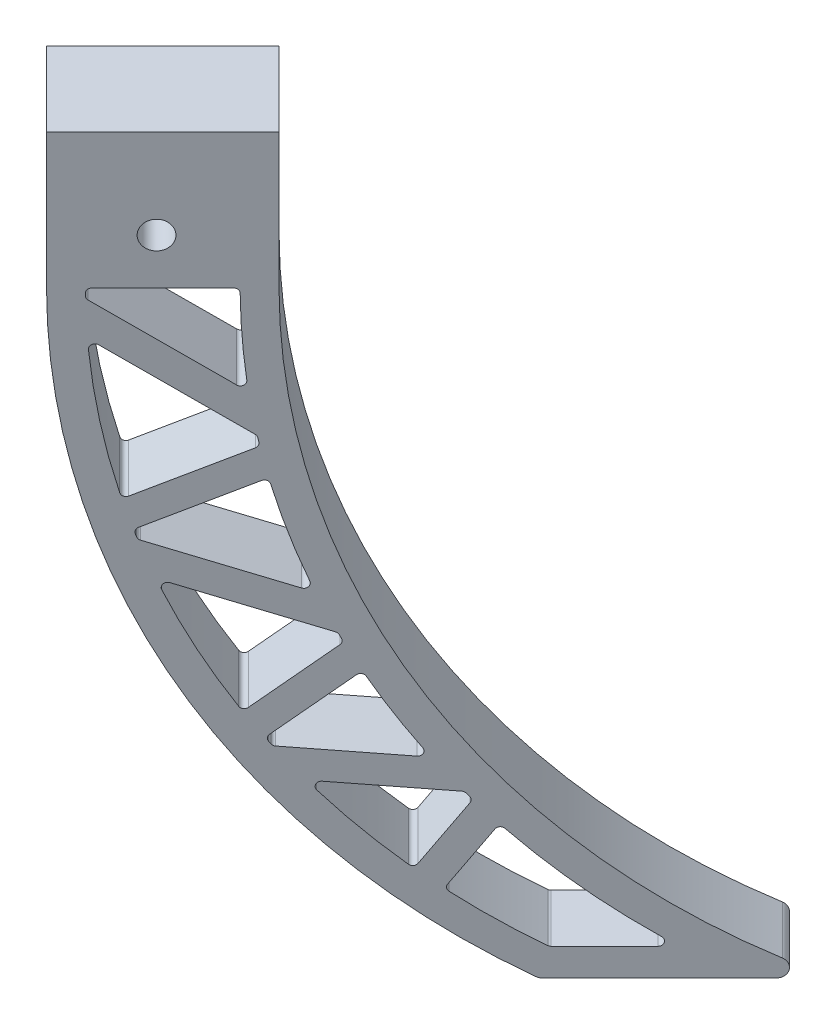
from build123d import *

# Parameters (mm, degrees)
BOSS_EXTRUDE1_DEPTH      = 40
BOSS_EXTRUDE1_DEPTH_BACK = 40
CUT_EXTRUDE1_DEPTH       = 30
CUT_EXTRUDE1_DEPTH_BACK  = 207.92123274
SKETCH3_R                = 1.5
CUT_EXTRUDE2_DEPTH       = 206.675682312
FILLET1_R                = 1
CUT_EXTRUDE3_DEPTH       = 40
FILLET2_R                = 0.5


with BuildPart() as part:
    # Sketch1 → Boss-Extrude1 (new, two sides: drawn at the far end of the back side and taken through both)
    with BuildSketch(Plane(origin=(61.148873397, 0, -61.148873397), x_dir=(0.7071067811865499, 0, 0.7071067811865452), z_dir=(-0.7071067811865452, 0, 0.7071067811865499)).offset(-BOSS_EXTRUDE1_DEPTH_BACK)):
        Polygon((-3.75, -92.901515315), (-3.75, -84.066578824), (-7.75, -81.757177748), (-7.75, -79.151515315), (3.75, -79.151515315), (3.75, -92.901515315), (3.75, -159.151515315), (-3.75, -159.151515315), align=None)
    extrude(amount=BOSS_EXTRUDE1_DEPTH + BOSS_EXTRUDE1_DEPTH_BACK)

    # Sketch2 → Cut-Extrude1 (cut, two sides: drawn at the far end of the back side and taken through both)
    with BuildSketch(Plane(origin=(-2.651650429, 0, -2.651650429), x_dir=(-0.7071067811865454, 0, 0.7071067811865498), z_dir=(-0.7071067811865498, 0, -0.7071067811865454)).offset(-CUT_EXTRUDE1_DEPTH_BACK)):
        with BuildLine():
            Line((-83.584702548, -79.151515315), (-83.584702548, -93.901515315))
            ThreePointArc((-83.584702548, -93.901515315), (-95.268174411, -132.944313121), (-126.477566081, -159.151515315))
            Line((-126.477566081, -159.151515315), (-126.477566081, -79.151515315))
            Line((-126.477566081, -79.151515315), (-83.584702548, -79.151515315))
        make_face()
        with BuildLine():
            Line((-65.634702548, -93.901515315), (-65.634702548, -79.151515315))
            Line((-65.634702548, -79.151515315), (-46.477566081, -79.151515315))
            Line((-46.477566081, -79.151515315), (-46.477566081, -159.151515315))
            Line((-46.477566081, -159.151515315), (-103.655823441, -159.151515315))
            ThreePointArc((-103.655823441, -159.151515315), (-75.833406523, -131.661176774), (-65.634702548, -93.901515315))
        make_face()
    extrude(amount=CUT_EXTRUDE1_DEPTH + CUT_EXTRUDE1_DEPTH_BACK, mode=Mode.SUBTRACT)

    # Sketch3 → Cut-Extrude2 (cut, through all)
    with BuildSketch(Plane(origin=(2.651650429, 0, 2.651650429), x_dir=(0.7071067811865454, 0, -0.7071067811865498), z_dir=(0.7071067811865498, 0, 0.7071067811865454))):
        with Locations((74.128214207, -88.901515315)):
            Circle(SKETCH3_R)
    extrude(amount=-CUT_EXTRUDE2_DEPTH, mode=Mode.SUBTRACT)

    # Fillet1
    fillet1_edges = [part.edges().sort_by_distance(p)[0] for p in [
        (73.295735665, -159.151515315, -73.295735665),
        (89.433144644, -159.151515315, -89.433144644),
    ]]
    fillet(fillet1_edges, radius=FILLET1_R)

    # Sketch4 → Cut-Extrude3 (cut)
    with BuildSketch(Plane(origin=(-2.651650429, 0, -2.651650429), x_dir=(-0.7071067811865454, 0, 0.7071067811865498), z_dir=(-0.7071067811865498, 0, -0.7071067811865454))):
        with BuildLine():
            ThreePointArc((-68.641647327, -94.901515315), (-68.636438764, -94.401527372), (-68.634702548, -93.901515315))
            Line((-68.634702548, -93.901515315), (-80.584702548, -93.901515315))
            ThreePointArc((-80.584702548, -93.901515315), (-80.748343571, -98.82260697), (-81.238542868, -103.721956531))
            Line((-81.238542868, -103.721956531), (-68.641647327, -94.901515315))
        make_face()
        with BuildLine():
            ThreePointArc((-71.446777789, -113.827153762), (-69.713665767, -106.319507983), (-68.79275862, -98.669648347))
            Line((-68.79275862, -98.669648347), (-81.910741312, -107.854958715))
            ThreePointArc((-81.910741312, -107.854958715), (-82.008492364, -108.355301003), (-82.109684478, -108.854958715))
            Line((-82.109684478, -108.854958715), (-71.446777789, -113.827153762))
        make_face()
        with BuildLine():
            ThreePointArc((-72.669081723, -117.664393631), (-72.505700586, -117.19183716), (-72.34560503, -116.718157493))
            Line((-72.34560503, -116.718157493), (-82.791324081, -111.847238704))
            ThreePointArc((-82.791324081, -111.847238704), (-84.384922058, -117.323155489), (-86.395070265, -122.660244896))
            Line((-86.395070265, -122.660244896), (-72.669081723, -117.664393631))
        make_face()
        with BuildLine():
            ThreePointArc((-80.784042437, -133.925239334), (-77.121371127, -127.814001685), (-74.080630429, -121.370688662))
            Line((-74.080630429, -121.370688662), (-88.136449193, -126.48658831))
            ThreePointArc((-88.136449193, -126.48658831), (-88.357906284, -126.934873492), (-88.582384151, -127.381653678))
            Line((-88.582384151, -127.381653678), (-80.784042437, -133.925239334))
        make_face()
        with BuildLine():
            ThreePointArc((-83.105887337, -137.19626581), (-82.806616537, -136.795716185), (-82.510134547, -136.393097949))
            Line((-82.510134547, -136.393097949), (-90.024605255, -130.087708349))
            ThreePointArc((-90.024605255, -130.087708349), (-92.547245897, -134.264707863), (-95.339415884, -138.266560873))
            Line((-95.339415884, -138.266560873), (-83.105887337, -137.19626581))
        make_face()
        with BuildLine():
            ThreePointArc((-94.002421329, -148.759790428), (-89.676742116, -144.76688928), (-85.691714117, -140.433955852))
            Line((-85.691714117, -140.433955852), (-97.902966063, -141.502301965))
            ThreePointArc((-97.902966063, -141.502301965), (-98.225553246, -141.884323374), (-98.550711636, -142.264158692))
            Line((-98.550711636, -142.264158692), (-94.002421329, -148.759790428))
        make_face()
        with BuildLine():
            ThreePointArc((-104.455461262, -156.151515315), (-100.301370683, -153.543969496), (-96.334442354, -150.659659636))
            Line((-96.334442354, -150.659659636), (-100.609312238, -144.554512732))
            ThreePointArc((-100.609312238, -144.554512732), (-107.203125114, -150.779152155), (-114.508069897, -156.151515315))
            Line((-114.508069897, -156.151515315), (-104.455461262, -156.151515315))
        make_face()
    extrude(amount=-CUT_EXTRUDE3_DEPTH, mode=Mode.SUBTRACT)

    # Fillet2
    fillet2_edges = [part.edges().sort_by_distance(p)[0] for p in [
        (80.969432725, -156.151515315, -80.969432725),
        (71.141526934, -144.554512732, -71.141526934),
        (68.11873745, -150.659659636, -68.11873745),
        (73.86116499, -156.151515315, -73.86116499),
        (66.46974957, -148.759790428, -66.46974957),
        (60.593192144, -140.433955852, -60.593192144),
        (69.227851202, -141.502301965, -69.227851202),
        (69.685876488, -142.264158692, -69.685876488),
        (67.415147486, -138.266560873, -67.415147486),
        (63.65700885, -130.087708349, -63.65700885),
        (58.343475655, -136.393097949, -58.343475655),
        (58.764736493, -137.19626581, -58.764736493),
        (57.122944219, -133.925239334, -57.122944219),
        (52.382916131, -121.370688662, -52.382916131),
        (62.321880894, -126.48658831, -62.321880894),
        (62.637204527, -127.381653678, -62.637204527),
        (61.090540045, -122.660244896, -61.090540045),
        (58.542306681, -111.847238704, -58.542306681),
        (51.156067906, -116.718157493, -51.156067906),
        (51.384800469, -117.664393631, -51.384800469),
        (50.520501068, -113.827153762, -50.520501068),
        (48.643826116, -98.669648347, -48.643826116),
        (57.919640634, -107.854958715, -57.919640634),
        (58.060314695, -108.854958715, -58.060314695),
        (57.444324556, -103.721956531, -57.444324556),
        (56.981989631, -93.901515315, -56.981989631),
        (48.536974297, -94.901515315, -48.536974297),
        (48.532063596, -93.901515315, -48.532063596),
    ]]
    fillet(fillet2_edges, radius=FILLET2_R)


solid = part.part
